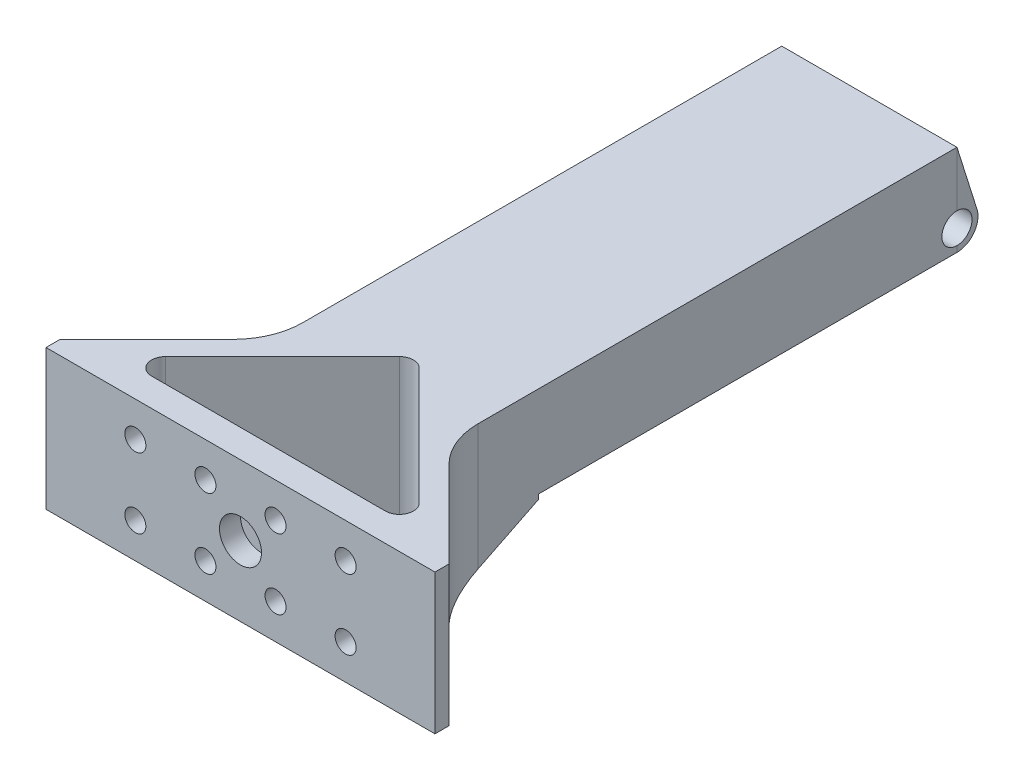
from build123d import *

# Parameters (mm, degrees)
EXTRUDE_1_DEPTH     = 20
SKETCH_2_R          = 1.5
CUT_EXTRUDE_1_DEPTH = 5
SKETCH_3_R          = 3
CUT_EXTRUDE_2_DEPTH = 3
SKETCH_4_W          = 24.99770673
SKETCH_4_H          = 59.73
CUT_EXTRUDE_3_DEPTH = 7
EXTRUDE_2_DEPTH     = 25
SKETCH_6_R          = 2.15
CUT_EXTRUDE_4_DEPTH = 41.24770673
CUT_EXTRUDE_9_DEPTH = 10
FILLET_3_R          = 10
FILLET_4_R          = 10


with BuildPart() as part:
    # 스케치1 → 보스-돌출1 (new body)
    with BuildSketch(Plane(origin=(0, 0, 0), x_dir=(1, 0, 0), z_dir=(0, 1, 0))):
        Polygon((40.24770673, 89.73229327), (15.25229327, 89.73229327), (15.25229327, 17.25229327), (0, 2), (0, 0), (55.5, 0), (55.5, 2), (40.24770673, 17.25229327), align=None)
        with BuildLine():
            Line((11.071067812, 4), (44.428932188, 4))
            ThreePointArc((44.428932188, 4), (46.276691253, 5.234633135), (45.843145751, 7.414213562))
            Line((45.843145751, 7.414213562), (29.164213562, 24.093145751))
            ThreePointArc((29.164213562, 24.093145751), (27.75, 24.678932188), (26.335786438, 24.093145751))
            Line((26.335786438, 24.093145751), (9.656854249, 7.414213562))
            ThreePointArc((9.656854249, 7.414213562), (9.223308747, 5.234633135), (11.071067812, 4))
        make_face(mode=Mode.SUBTRACT)
    extrude(amount=EXTRUDE_1_DEPTH)

    # 스케치2 → 컷-돌출1 (cut)
    with BuildSketch(Plane.XY):
        with Locations((12.75, 15)):
            Circle(SKETCH_2_R)
        with Locations((22.75, 15)):
            Circle(SKETCH_2_R)
        with Locations((32.75, 15)):
            Circle(SKETCH_2_R)
        with Locations((42.75, 15)):
            Circle(SKETCH_2_R)
        with Locations((42.75, 5)):
            Circle(SKETCH_2_R)
        with Locations((32.75, 5)):
            Circle(SKETCH_2_R)
        with Locations((22.75, 5)):
            Circle(SKETCH_2_R)
        with Locations((12.75, 5)):
            Circle(SKETCH_2_R)
    extrude(amount=-CUT_EXTRUDE_1_DEPTH, mode=Mode.SUBTRACT)

    # 스케치3 → 컷-돌출2 (cut)
    with BuildSketch(Plane.XY):
        with Locations((27.75, 10)):
            Circle(SKETCH_3_R)
    extrude(amount=-CUT_EXTRUDE_2_DEPTH, mode=Mode.SUBTRACT)

    # 스케치4 → 컷-돌출3 (cut)
    with BuildSketch(Plane.XZ):
        with Locations((27.748853365, -59.86729327)):
            Rectangle(SKETCH_4_W, SKETCH_4_H)
    extrude(amount=-CUT_EXTRUDE_3_DEPTH, mode=Mode.SUBTRACT)

    # 스케치5 → 보스-돌출2 (add)
    with BuildSketch(Plane.ZY.offset(-15.25229327)):
        with BuildLine():
            Line((-89.73229327, 20), (-92.624677966, 10.804147089))
            ThreePointArc((-92.624677966, 10.804147089), (-92.122576041, 8.184258847), (-89.73229327, 7))
            Line((-89.73229327, 7), (-89.73229327, 20))
        make_face()
    extrude(amount=-EXTRUDE_2_DEPTH)

    # 스케치6 → 컷-돌출4 (cut, through all)
    with BuildSketch(Plane.ZY.offset(-15.25229327)):
        with Locations((-89.734462369, 9.999999216)):
            Circle(SKETCH_6_R)
    extrude(amount=-CUT_EXTRUDE_4_DEPTH, mode=Mode.SUBTRACT)

    # 스케치12 → 컷-돌출9 (cut)
    with BuildSketch(Plane(origin=(9.45846044, -19.103311951, -9.45846044), x_dir=(-0.707106781, 0, -0.707106781), z_dir=(0.405579788, -0.819152044, -0.405579788))):
        Polygon((-16.260212793, 33.305608007), (3.048063237, 33.305608007), (-6.606074778, 45.231574441), align=None)
    cut_extrude_9 = extrude(amount=CUT_EXTRUDE_9_DEPTH, mode=Mode.SUBTRACT)

    # 대칭 복사2: 컷-돌출9 across plane
    add(cut_extrude_9.mirror(Plane(origin=(27.74770673, 0, 0), x_dir=(0, 0, 1), z_dir=(1, 0, 0))), mode=Mode.SUBTRACT)

    # 필렛3
    fillet_3_edges = [part.edges().sort_by_distance(p)[0] for p in [
        (27.74770673, 0.061890187, -29.87729327),
    ]]
    fillet(fillet_3_edges, radius=FILLET_3_R)

    # 필렛4
    fillet_4_edges = [part.edges().sort_by_distance(p)[0] for p in [
        (15.25229327, 10, -17.25229327),
        (40.24770673, 10, -17.25229327),
    ]]
    fillet(fillet_4_edges, radius=FILLET_4_R)


solid = part.part
